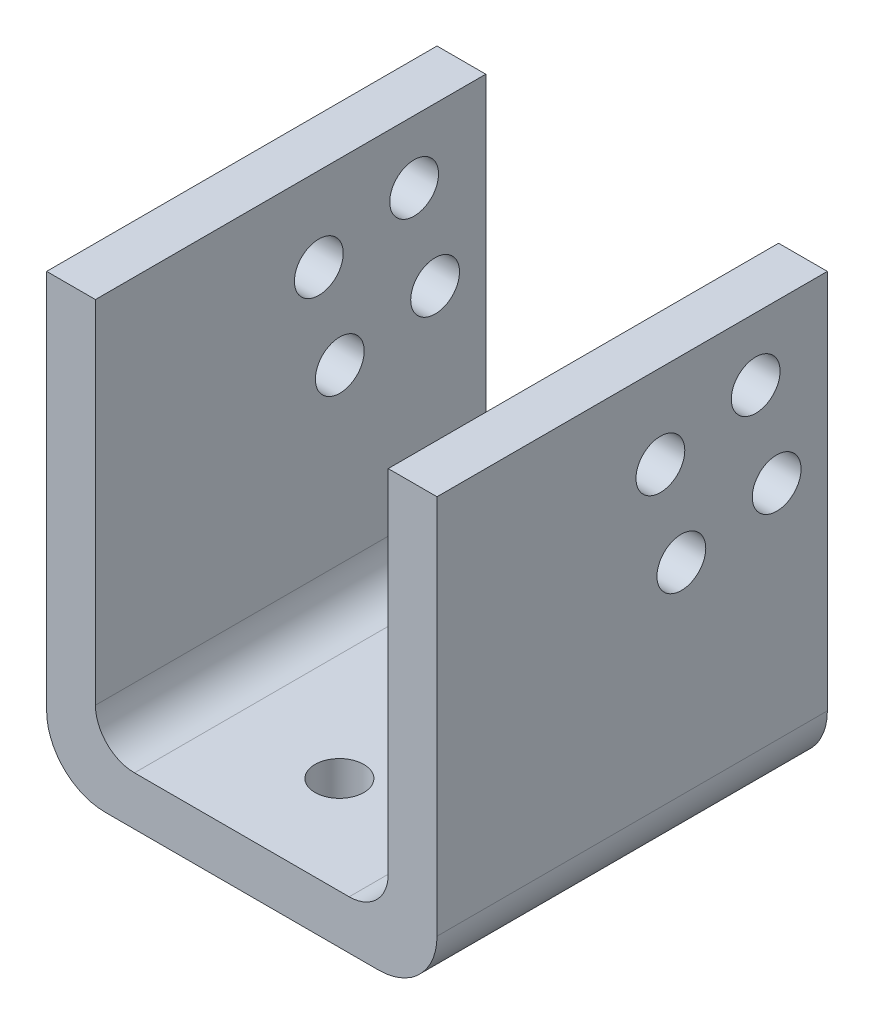
from build123d import *

# Parameters (mm, degrees)
RESSALTO_EXTRUS_O1_DEPTH = 40
FILETE1_R                = 6
ESBO_O3_R                = 2.5
CORTE_EXTRUS_O1_DEPTH    = 60
FILETE2_R                = 4
ESBO_O6_R                = 2.5
CORTE_EXTRUS_O4_DEPTH    = 5


with BuildPart() as part:
    # Esboço1 → Ressalto-extrusão1 (new body)
    with BuildSketch(Plane.XY):
        Polygon((0, 0), (0, 45), (5, 45), (5, 5), (35, 5), (35, 45), (40, 45), (40, 0), align=None)
    extrude(amount=RESSALTO_EXTRUS_O1_DEPTH)

    # Filete1
    filete1_edges = [part.edges().sort_by_distance(p)[0] for p in [
        (0, 0, 20),
        (40, 0, 20),
    ]]
    fillet(filete1_edges, radius=FILETE1_R)

    # Esboço3 → Corte-extrusão1 (cut)
    with BuildSketch(Plane.ZY):
        with Locations((7.342858474, 38.577006564)):
            Circle(ESBO_O3_R)
        with Locations((17.109227068, 36.428042981)):
            Circle(ESBO_O3_R)
        with Locations((14.960263485, 26.661674387)):
            Circle(ESBO_O3_R)
        with Locations((5.193894891, 28.810637969)):
            Circle(ESBO_O3_R)
    extrude(amount=-CORTE_EXTRUS_O1_DEPTH, mode=Mode.SUBTRACT)

    # Filete2
    filete2_edges = [part.edges().sort_by_distance(p)[0] for p in [
        (5, 5, 20),
        (35, 5, 20),
    ]]
    fillet(filete2_edges, radius=FILETE2_R)

    # Esboço6 → Corte-extrusão4 (cut)
    with BuildSketch(Plane.XZ):
        with Locations((20, 30)):
            Circle(ESBO_O6_R)
        with Locations((20, 10)):
            Circle(ESBO_O6_R)
    extrude(amount=-CORTE_EXTRUS_O4_DEPTH, mode=Mode.SUBTRACT)


solid = part.part
